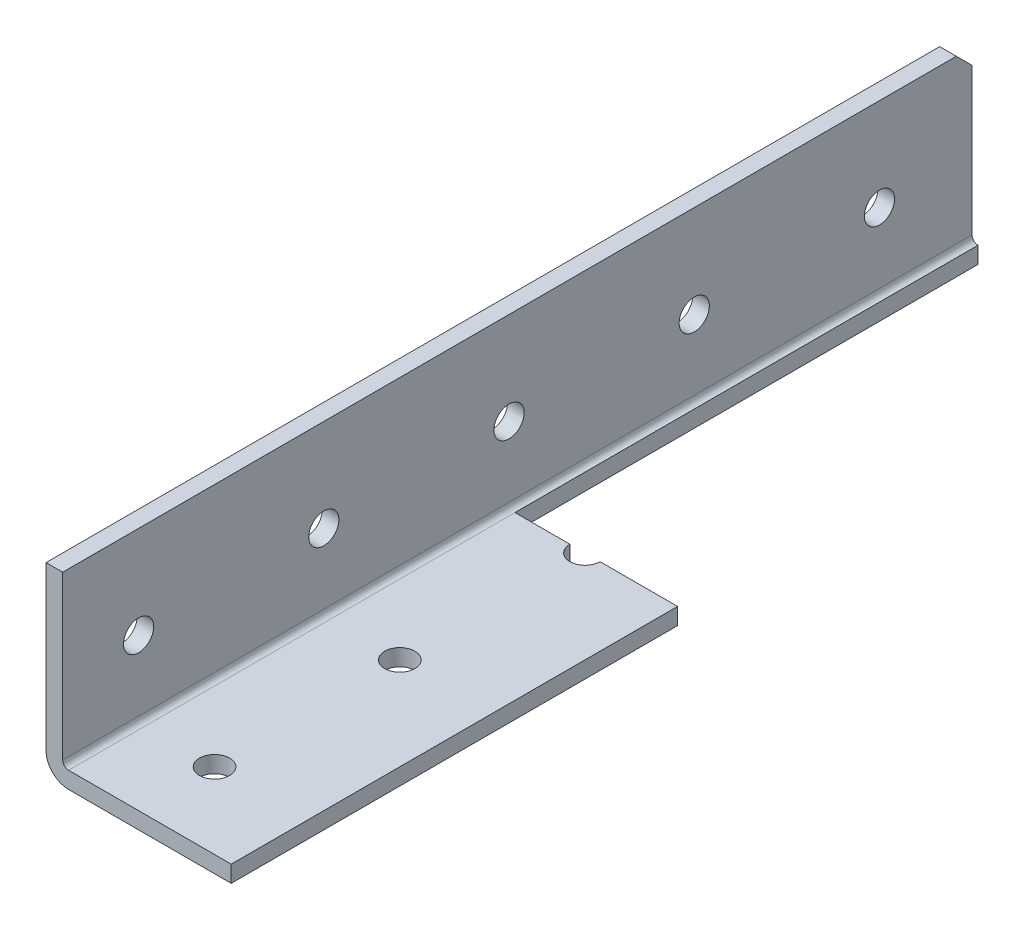
from build123d import *

# Parameters (mm, degrees)
SKETCH1_W                  = 25.4
SKETCH1_H                  = 1498.6
BOSS_EXTRUDE1_DEPTH        = 25.4
SKETCH2_W                  = 23.114
SKETCH2_H                  = 23.114
CUT_EXTRUDE1_DEPTH         = 1499.6
M3_5_CLEARANCE_HOLE1_D     = 4.1402
M3_5_CLEARANCE_HOLE1_DEPTH = 25.4
M3_5_CLEARANCE_HOLE2_D     = 4.1402
M3_5_CLEARANCE_HOLE2_DEPTH = 25.4
CHAMFER1_SIZE              = 2.159
FILLET1_R                  = 0.8128
FILLET2_R                  = 3.0988
SKETCH8_W                  = 95.882963774
SKETCH8_H                  = 79.338329604
CUT_EXTRUDE3_DEPTH         = 1371.6
SKETCH11_W                 = 51.462522779
SKETCH11_H                 = 66.676735099
CUT_EXTRUDE6_DEPTH         = 2.286
SKETCH12_W                 = 24.634530663
SKETCH12_H                 = 66.668992962
CUT_EXTRUDE7_DEPTH         = 2.54


with BuildPart() as part:
    # Sketch1 → Boss-Extrude1 (new body)
    with BuildSketch(Plane(origin=(0, 0, 0), x_dir=(0, -1, 0), z_dir=(-1, 0, 0))):
        with Locations((-12.7, 0)):
            Rectangle(SKETCH1_W, SKETCH1_H)
    extrude(amount=-BOSS_EXTRUDE1_DEPTH)

    # Sketch2 → Cut-Extrude1 (cut, through all)
    with BuildSketch(Plane(origin=(0, 0, -749.3), x_dir=(-1, 0, 0), z_dir=(0, 0, -1))):
        with Locations((-13.843, 13.843)):
            Rectangle(SKETCH2_W, SKETCH2_H)
    extrude(amount=-CUT_EXTRUDE1_DEPTH, mode=Mode.SUBTRACT)

    # M3.5 Clearance Hole1
    with Locations(Plane(origin=(0, 0, 0), x_dir=(-1, 0, 0), z_dir=(0, -1, 0))):
        with Locations((-12.7, 736.6), (-12.7, 711.2), (-12.7, 685.8), (-12.7, 660.4), (-12.7, 635), (-12.7, 609.6), (-12.7, 584.2), (-12.7, 558.8), (-12.7, 533.4), (-12.7, 508), (-12.7, 482.6), (-12.7, 457.2), (-12.7, 431.8), (-12.7, 406.4), (-12.7, 381), (-12.7, 355.6), (-12.7, 330.2), (-12.7, 304.8), (-12.7, 279.4), (-12.7, 254), (-12.7, 228.6), (-12.7, 203.2), (-12.7, 177.8), (-12.7, 152.4), (-12.7, 127), (-12.7, 101.6), (-12.7, 76.2), (-12.7, 50.8), (-12.7, 25.4), (-12.7, 0), (-12.7, -25.4), (-12.7, -50.8), (-12.7, -76.2), (-12.7, -101.6), (-12.7, -127), (-12.7, -152.4), (-12.7, -177.8), (-12.7, -203.2), (-12.7, -228.6), (-12.7, -254), (-12.7, -279.4), (-12.7, -304.8), (-12.7, -330.2), (-12.7, -355.6), (-12.7, -381), (-12.7, -406.4), (-12.7, -431.8), (-12.7, -457.2), (-12.7, -482.6), (-12.7, -508), (-12.7, -533.4), (-12.7, -558.8), (-12.7, -584.2), (-12.7, -609.6), (-12.7, -635), (-12.7, -660.4), (-12.7, -685.8), (-12.7, -711.2), (-12.7, -736.6)):
            Hole(M3_5_CLEARANCE_HOLE1_D / 2, depth=M3_5_CLEARANCE_HOLE1_DEPTH)

    # M3.5 Clearance Hole2
    with Locations(Plane.ZY):
        with Locations((711.2, 12.7), (736.6, 12.7), (685.8, 12.7), (660.4, 12.7), (635, 12.7), (609.6, 12.7), (584.2, 12.7), (558.8, 12.7), (533.4, 12.7), (508, 12.7), (482.6, 12.7), (457.2, 12.7), (431.8, 12.7), (406.4, 12.7), (381, 12.7), (355.6, 12.7), (330.2, 12.7), (304.8, 12.7), (279.4, 12.7), (254, 12.7), (228.6, 12.7), (203.2, 12.7), (177.8, 12.7), (152.4, 12.7), (127, 12.7), (101.6, 12.7), (76.2, 12.7), (50.8, 12.7), (25.4, 12.7), (0, 12.7), (-25.4, 12.7), (-50.8, 12.7), (-76.2, 12.7), (-101.6, 12.7), (-127, 12.7), (-152.4, 12.7), (-177.8, 12.7), (-203.2, 12.7), (-228.6, 12.7), (-254, 12.7), (-279.4, 12.7), (-304.8, 12.7), (-330.2, 12.7), (-355.6, 12.7), (-381, 12.7), (-406.4, 12.7), (-431.8, 12.7), (-457.2, 12.7), (-482.6, 12.7), (-508, 12.7), (-533.4, 12.7), (-558.8, 12.7), (-584.2, 12.7), (-609.6, 12.7), (-635, 12.7), (-660.4, 12.7), (-685.8, 12.7), (-711.2, 12.7), (-736.6, 12.7)):
            Hole(M3_5_CLEARANCE_HOLE2_D / 2, depth=M3_5_CLEARANCE_HOLE2_DEPTH)

    # Chamfer1
    chamfer1_edges = [part.edges().sort_by_distance(p)[0] for p in [
        (25.4, 1.143, -749.3),
        (1.143, 25.4, 749.3),
        (1.143, 25.4, -749.3),
        (25.4, 1.143, 749.3),
    ]]
    chamfer(chamfer1_edges, length=CHAMFER1_SIZE)

    # Fillet1
    fillet1_edges = [part.edges().sort_by_distance(p)[0] for p in [
        (2.286, 2.286, 0),
    ]]
    fillet(fillet1_edges, radius=FILLET1_R)

    # Fillet2
    fillet2_edges = [part.edges().sort_by_distance(p)[0] for p in [
        (0, 0, 0),
    ]]
    fillet(fillet2_edges, radius=FILLET2_R)

    # Sketch8 → Cut-Extrude3 (cut)
    with BuildSketch(Plane.XY.offset(749.3)):
        with Locations((2.286, 3.0988)):
            Rectangle(SKETCH8_W, SKETCH8_H)
    extrude(amount=-CUT_EXTRUDE3_DEPTH, mode=Mode.SUBTRACT)

    # Sketch11 → Cut-Extrude6 (cut)
    with BuildSketch(Plane.XY.offset(-622.3)):
        with Locations((1.85517497, 1.74884985)):
            Rectangle(SKETCH11_W, SKETCH11_H)
    extrude(amount=-CUT_EXTRUDE6_DEPTH, mode=Mode.SUBTRACT)

    # Sketch12 → Cut-Extrude7 (cut)
    with BuildSketch(Plane(origin=(0, 2.286, 0), x_dir=(1, 0, 0), z_dir=(0, 1, 0))):
        with Locations((15.416065332, 719.134496481)):
            Rectangle(SKETCH12_W, SKETCH12_H)
    extrude(amount=-CUT_EXTRUDE7_DEPTH, mode=Mode.SUBTRACT)


solid = part.part
